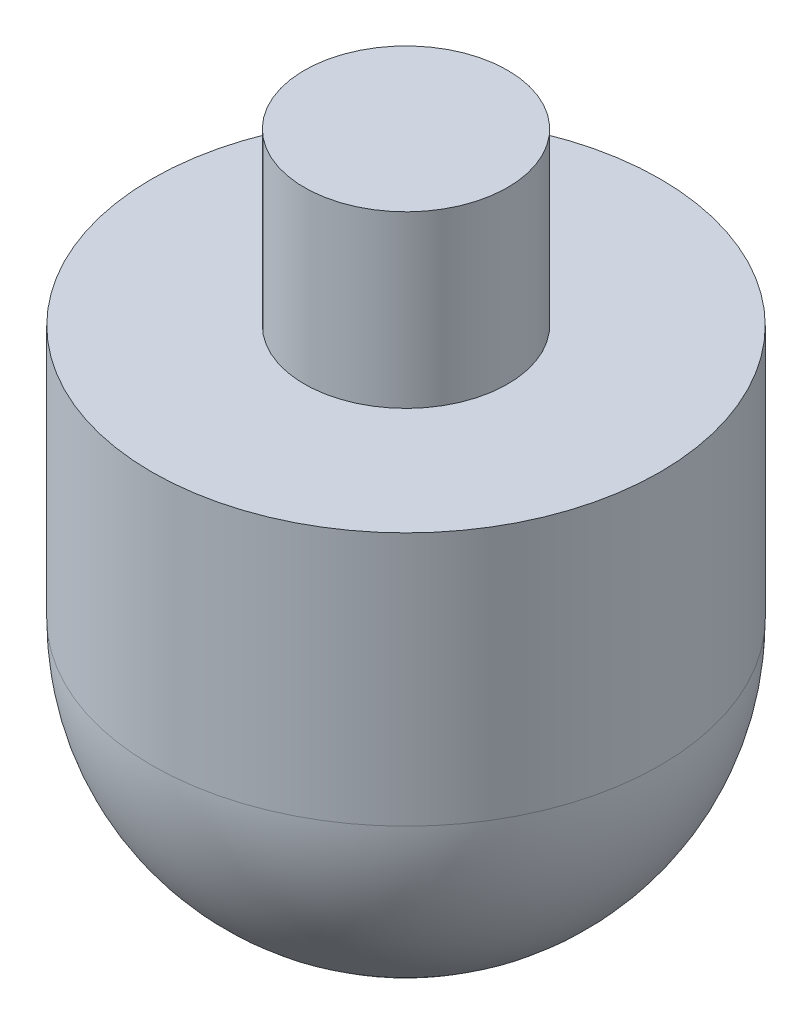
from build123d import *


with BuildPart() as part:
    # Sketch1 → Revolve1 (revolve)
    with BuildSketch(Plane.XY, mode=Mode.PRIVATE) as revolve1_sk:
        with BuildLine():
            Line((150, 0), (150, 150))
            Line((150, 150), (60, 150))
            Line((60, 150), (60, 250.529628205))
            Line((60, 250.529628205), (0, 250.529628205))
            Line((0, 250.529628205), (0, -150))
            ThreePointArc((0, -150), (106.066017178, -106.066017178), (150, 0))
        make_face()
    revolve(revolve1_sk.sketch.rotate(Axis((0, 0, 0), (0, 1, 0)), 90), axis=Axis((0, 0, 0), (0, 1, 0)))  # turned: the seam where the file's is


solid = part.part
